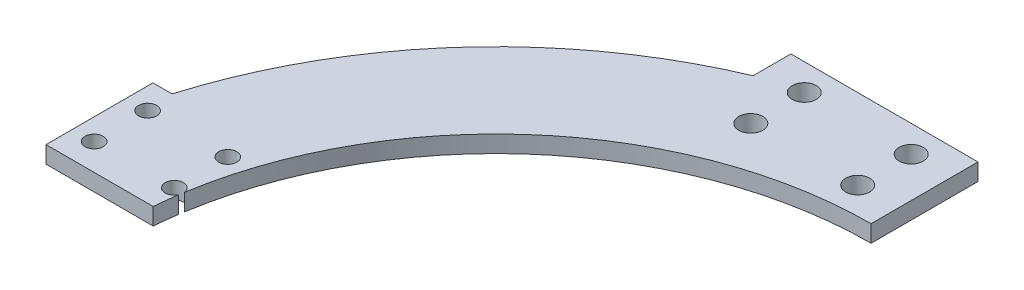
from build123d import *

# Parameters (mm, degrees)
BOSS_EXTRUDE1_DEPTH  = 3.175
BOSS_EXTRUDE2_DEPTH  = 3.175
M4_CLEARANCE_HOLE1_D = 4.5
SKETCH7_R            = 1.7
CUT_EXTRUDE1_DEPTH   = 4.175


with BuildPart() as part:
    # Sketch1 → Boss-Extrude1 (new body)
    with BuildSketch(Plane(origin=(0, 0, 0), x_dir=(1, 0, 0), z_dir=(0, 1, 0))):
        with BuildLine():
            ThreePointArc((0, 85), (-61.668691787, 60.61327124), (-89.979209979, 0.644490644))
            Line((-89.979209979, 0.644490644), (-69.92561449, 0.644490644))
            ThreePointArc((-69.92561449, 0.644490644), (-47.516373878, 46.462349638), (0, 65))
            Line((0, 65), (0, 85))
        make_face()
    extrude(amount=BOSS_EXTRUDE1_DEPTH)

    # Sketch2 → Boss-Extrude2 (add)
    with BuildSketch(Plane(origin=(0, 3.175, 0), x_dir=(1, 0, 0), z_dir=(0, 1, 0))):
        with BuildLine():
            Line((-89.979209979, 20.644490644), (-89.979209979, 0.644490644))
            ThreePointArc((-89.979209979, 0.644490644), (-88.75145348, 10.745821604), (-86.393355856, 20.644490644))
            Line((-86.393355856, 20.644490644), (-89.979209979, 20.644490644))
        make_face()
        with BuildLine():
            Line((-35, 85), (-35, 77.929830117))
            ThreePointArc((-35, 77.929830117), (-17.853482169, 83.214784737), (0, 85))
            Line((0, 85), (-35, 85))
        make_face()
    extrude(amount=-BOSS_EXTRUDE2_DEPTH)

    # M4 Clearance Hole1 (through all)
    with Locations(Plane.XZ):
        with Locations((-27.5, -70), (-7.5, -80), (-27.5, -80), (-7.5, -70)):
            Hole(M4_CLEARANCE_HOLE1_D / 2)

    # Sketch7 → Cut-Extrude1 (cut, through all)
    with BuildSketch(Plane.XZ):
        with Locations((-70.979209979, -15.644490644)):
            Circle(SKETCH7_R)
        with Locations((-85.979209979, -15.644490644)):
            Circle(SKETCH7_R)
        with Locations((-85.979209979, -5.644490644)):
            Circle(SKETCH7_R)
        with Locations((-70.979209979, -5.644490644)):
            Circle(SKETCH7_R)
    extrude(amount=-CUT_EXTRUDE1_DEPTH, mode=Mode.SUBTRACT)


solid = part.part
